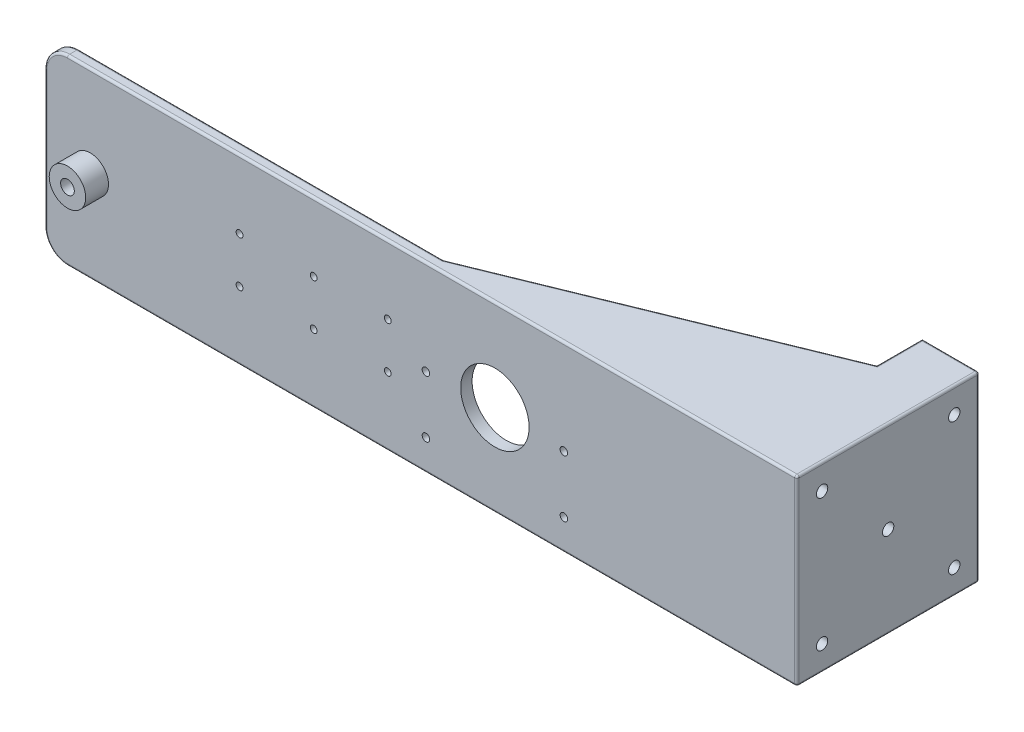
from build123d import *

# Parameters (mm, degrees)
SKETCH_1_W               = 330
SKETCH_1_H               = 80
EXTRUDE_1_DEPTH          = 5
SKETCH_2_R               = 5
CUT_EXTRUDE_1_DEPTH      = 5
SKETCH_3_R               = 4
CUT_EXTRUDE_2_DEPTH      = 10
SKETCH_4_W               = 88
SKETCH_4_H               = 20
EXTRUDE_2_DEPTH          = 10
SKETCH_5_R               = 15
CUT_EXTRUDE_3_DEPTH      = 10
SKETCH_6_R               = 8
EXTRUDE_3_DEPTH          = 15
F_6_0MM_1_D              = 6
CUT_EXTRUDE_4_DEPTH      = 7
HOLE_WIZARD_M4_1_D       = 3.3
FILLET_1_R               = 10
SKETCH_13_R              = 6.969385005
EXTRUDE_5_DEPTH          = 5
SKETCH_14_W              = 5
SKETCH_14_H              = 75
EXTRUDE_6_DEPTH          = 80
SKETCH_15_W              = 20
SKETCH_15_H              = 5
EXTRUDE_7_DEPTH          = 80
EXTRUDE_8_DEPTH          = 5
SKETCH_17_R              = 3
CUT_EXTRUDE_5_DEPTH      = 5
FILLET_2_R               = 1
FILLET_3_R               = 1
CUT_EXTRUDE_6_DEPTH      = 100
F_3_0MM_1_D              = 3
F_3_0MM_1_DEPTH          = 7.5
F_3_0MM_1_TIP            = 0.901290929
SKETCH_21_R              = 2.5
CUT_EXTRUDE_7_DEPTH      = 10
PATTERN_CIRCULAR_1_COUNT = 4
CUT_EXTRUDE_START        = -5
SKETCH_25_R              = 5.25
CUT_EXTRUDE_8_DEPTH      = 86


with BuildPart() as part:
    # 草图1 → 凸台-拉伸1 (new body)
    with BuildSketch(Plane.XY):
        Rectangle(SKETCH_1_W, SKETCH_1_H)
    extrude(amount=EXTRUDE_1_DEPTH)

    # 草图2 → 切除-拉伸1 (cut)
    with BuildSketch(Plane.XY.offset(5)):
        with Locations((-145, 0)):
            Circle(SKETCH_2_R)
    extrude(amount=-CUT_EXTRUDE_1_DEPTH, mode=Mode.SUBTRACT)

    # 草图3 → 切除-拉伸2 (cut)
    with BuildSketch(Plane.XY.offset(5)):
        with Locations((-45, 0)):
            Circle(SKETCH_3_R)
    extrude(amount=-CUT_EXTRUDE_2_DEPTH, mode=Mode.SUBTRACT)

    # 草图4 → 凸台-拉伸2 (add)
    with BuildSketch(Plane.XY.offset(5)):
        with Locations((-47, 0)):
            Rectangle(SKETCH_4_W, SKETCH_4_H)
    extrude(amount=EXTRUDE_2_DEPTH)

    # 草图5 → 切除-拉伸3 (cut)
    with BuildSketch(Plane.XY.offset(5)):
        with Locations((32.5, 0)):
            Circle(SKETCH_5_R)
    extrude(amount=-CUT_EXTRUDE_3_DEPTH, mode=Mode.SUBTRACT)

    # 草图6 → 凸台-拉伸3 (add)
    with BuildSketch(Plane(origin=(0, 0, 0), x_dir=(-1, 0, 0), z_dir=(0, 0, -1))):
        with Locations((145, 0)):
            Circle(SKETCH_6_R)
    extrude(amount=-EXTRUDE_3_DEPTH)

    # Ø6.0mm 暗销孔1 (through all)
    with Locations(Plane.XY.offset(15)):
        with Locations((-145, 0)):
            Hole(F_6_0MM_1_D / 2)

    # 草图10 → 切除-拉伸4 (cut)
    with BuildSketch(Plane.XY.offset(15)):
        with BuildLine():
            Line((-91, 5.1), (-3, 5.1))
            ThreePointArc((-3, 5.1), (2.1, 0), (-3, -5.1))
            Line((-3, -5.1), (-91, -5.1))
            ThreePointArc((-91, -5.1), (-96.1, 0), (-91, 5.1))
        make_face()
    extrude(amount=-CUT_EXTRUDE_4_DEPTH, mode=Mode.SUBTRACT)

    # M4 螺纹孔1 (through all)
    with Locations(Plane(origin=(0, 0, 0), x_dir=(-1, 0, 0), z_dir=(0, 0, -1))):
        with Locations((-2.25, -26.5), (-2.25, -1.5), (-62.75, -26.5), (-62.75, -1.5)):
            Hole(HOLE_WIZARD_M4_1_D / 2)

    # 圆角1
    fillet_1_edges = [part.edges().sort_by_distance(p)[0] for p in [
        (-165, 40, 2.5),
        (-165, -40, 2.5),
    ]]
    fillet(fillet_1_edges, radius=FILLET_1_R)

    # 草图13 → 凸台-拉伸5 (add)
    with BuildSketch(Plane.XY.offset(5)):
        with Locations((-45, 0)):
            Circle(SKETCH_13_R)
    extrude(amount=-EXTRUDE_5_DEPTH)

    # 草图14 → 凸台-拉伸6 (add)
    with BuildSketch(Plane.XZ.offset(40)):
        with Locations((162.5, -37.5)):
            Rectangle(SKETCH_14_W, SKETCH_14_H)
    extrude(amount=-EXTRUDE_6_DEPTH)

    # 草图15 → 凸台-拉伸7 (add)
    with BuildSketch(Plane.XZ.offset(40)):
        with Locations((150, -72.5)):
            Rectangle(SKETCH_15_W, SKETCH_15_H)
    extrude(amount=-EXTRUDE_7_DEPTH)

    # 草图16 → 凸台-拉伸8 (add)
    with BuildSketch(Plane.XZ.offset(40)):
        Polygon((5, 5), (5, 0), (140, -55), (140, -75), (165, -75), (165, 5), align=None)
    extrude_8 = extrude(amount=-EXTRUDE_8_DEPTH)

    # 镜向1: 凸台-拉伸8 across plane
    add(extrude_8.mirror(Plane.ZX))

    # 草图17 → 切除-拉伸5 (cut)
    with BuildSketch(Plane(origin=(0, 0, -75), x_dir=(-1, 0, 0), z_dir=(0, 0, -1))):
        with Locations((-152, -15)):
            Circle(SKETCH_17_R)
        with Locations((-152, 15)):
            Circle(SKETCH_17_R)
    extrude(amount=-CUT_EXTRUDE_5_DEPTH, mode=Mode.SUBTRACT)

    # 圆角2
    fillet_2_edges = [part.edges().sort_by_distance(p)[0] for p in [
        (-75, -40, 0),
        (5, -40, 5),
        (-165, 0, 0),
        (-162.071067812, 37.071067812, 0),
        (-162.071067812, -37.071067812, 0),
        (-165, 0, 5),
        (-162.071067812, 37.071067812, 5),
        (-162.071067812, -37.071067812, 5),
        (165, 0, -75),
        (165, 0, 5),
        (152.5, -40, -75),
        (152.5, 40, -75),
        (140, -40, -65),
        (140, 40, -65),
        (72.5, -40, -27.5),
        (5, 40, 5),
        (-75, 40, 0),
        (72.5, 40, -27.5),
        (165, 40, -35),
        (165, -40, -35),
    ]]
    fillet(fillet_2_edges, radius=FILLET_2_R)

    # 圆角3
    fillet_3_edges = [part.edges().sort_by_distance(p)[0] for p in [
        (-47, -10, 15),
        (-47, 10, 15),
        (-47, 5.1, 15),
        (-47, -5.1, 15),
    ]]
    fillet(fillet_3_edges, radius=FILLET_3_R)

    # 草图18 → 切除-拉伸6 (cut)
    with BuildSketch(Plane(origin=(-3, 0, 0), x_dir=(0, 0, -1), z_dir=(1, 0, 0))):
        with BuildLine():
            Line((-15, -6.1), (-15, -9))
            ThreePointArc((-15, -9), (-14.707106781, -9.707106781), (-14, -10))
            Line((-14, -10), (-5, -10))
            Line((-5, -10), (-5, 10))
            Line((-5, 10), (-14, 10))
            ThreePointArc((-14, 10), (-14.707106781, 9.707106781), (-15, 9))
            Line((-15, 9), (-15, 6.1))
            ThreePointArc((-15, 6.1), (-14.707106781, 5.392893219), (-14, 5.1))
            Line((-14, 5.1), (-8, 5.1))
            Line((-8, 5.1), (-8, -5.1))
            Line((-8, -5.1), (-14, -5.1))
            ThreePointArc((-14, -5.1), (-14.707106781, -5.392893219), (-15, -6.1))
        make_face()
    extrude(amount=-CUT_EXTRUDE_6_DEPTH, mode=Mode.SUBTRACT)

    # Ø3.0mm 暗销孔1
    with Locations(Plane.XY.offset(5)):
        with Locations((-14.5, -10), (-14.5, 10), (-47, 10), (-47, -10), (-79.5, -10), (-79.5, 10)):
            Hole(F_3_0MM_1_D / 2, depth=F_3_0MM_1_DEPTH)
            with Locations((0, 0, -(F_3_0MM_1_DEPTH + F_3_0MM_1_TIP / 2))):  # 118° drill point
                Cone(0, F_3_0MM_1_D / 2, F_3_0MM_1_TIP, mode=Mode.SUBTRACT)

    # 草图21 → 切除-拉伸7 (cut)
    with BuildSketch(Plane(origin=(165, 0, 0), x_dir=(0, 0, -1), z_dir=(1, 0, 0))):
        with Locations((35, 0)):
            Circle(SKETCH_21_R)
    extrude(amount=-CUT_EXTRUDE_7_DEPTH, mode=Mode.SUBTRACT)

    # 草图24 → Ø5.0mm 暗销孔1 (revolve, cut)
    with BuildSketch(Plane(origin=(165, 28.991378029, -6.008621971), x_dir=(0, 0, -1), z_dir=(0, 1, 0))):
        Polygon((0, 0), (0, 13.902151548), (2.5, 12.4), (2.5, 0), align=None)
    f_5_0mm_1 = revolve(axis=Axis((171.35, 28.991378029, -6.008621971), (-1, 0, 0)), mode=Mode.SUBTRACT)

    # 阵列(圆周)1: Ø5.0mm 暗销孔1 ×4 about axis
    pattern_circular_1_axis = Axis((0, 0, -35), (1, 0, 0))
    for i in range(1, PATTERN_CIRCULAR_1_COUNT):
        add(f_5_0mm_1.rotate(pattern_circular_1_axis, i * 360 / PATTERN_CIRCULAR_1_COUNT), mode=Mode.SUBTRACT)

    # 草图25 → 切除-拉伸8 (cut, through all)
    with BuildSketch(Plane.XY.offset(15).offset(CUT_EXTRUDE_START)):
        with Locations((-145, 0)):
            Circle(SKETCH_25_R)
    extrude(amount=-CUT_EXTRUDE_8_DEPTH, mode=Mode.SUBTRACT)


solid = part.part
